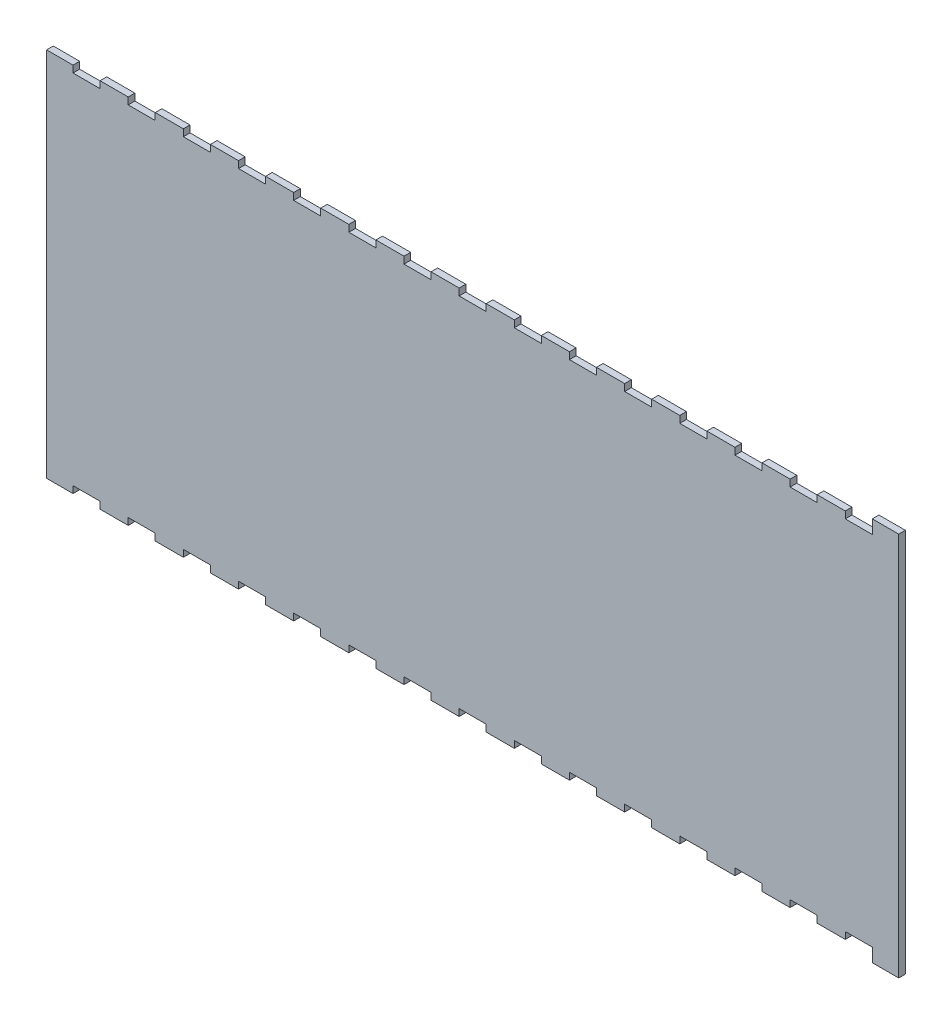
from build123d import *

# Parameters (mm, degrees)
BOSS_EXTRUDE1_DEPTH = 3.175


with BuildPart() as part:
    # Sketch1 → Boss-Extrude1 (new body)
    with BuildSketch(Plane.XY):
        Polygon((-12.6, 173.7122), (-25.5, 173.7122), (-25.5, 176.9872), (-38.907142857, 176.9872), (-38.907142857, 173.7122), (-51.807142857, 173.7122), (-51.807142857, 176.9872), (-65.214285714, 176.9872), (-65.214285714, 173.7122), (-78.114285714, 173.7122), (-78.114285714, 176.9872), (-91.521428571, 176.9872), (-91.521428571, 173.7122), (-104.421428571, 173.7122), (-104.421428571, 176.9872), (-117.828571429, 176.9872), (-117.828571429, 173.7122), (-130.728571429, 173.7122), (-130.728571429, 176.9872), (-144.135714286, 176.9872), (-144.135714286, 173.7122), (-157.035714286, 173.7122), (-157.035714286, 176.9872), (-170.442857143, 176.9872), (-170.442857143, 173.7122), (-183.342857143, 173.7122), (-183.342857143, 176.9872), (-196.75, 176.9872), (-196.75, 173.7122), (-209.65, 173.7122), (-209.65, 176.9872), (-223.057142857, 176.9872), (-223.057142857, 173.7122), (-235.957142857, 173.7122), (-235.957142857, 176.9872), (-249.364285714, 176.9872), (-249.364285714, 173.7122), (-262.264285714, 173.7122), (-262.264285714, 176.9872), (-275.671428571, 176.9872), (-275.671428571, 173.7122), (-288.571428571, 173.7122), (-288.571428571, 176.9872), (-301.978571429, 176.9872), (-301.978571429, 173.7122), (-314.878571429, 173.7122), (-314.878571429, 176.9872), (-328.285714286, 176.9872), (-328.285714286, 173.7122), (-341.185714286, 173.7122), (-341.185714286, 176.9872), (-354.592857143, 176.9872), (-354.592857143, 173.7122), (-367.492857143, 173.7122), (-367.492857143, 176.9872), (-380.9, 176.9872), (-380.9, 173.7122), (-393.8, 173.7122), (-393.8, 176.9872), (-406.4, 176.9872), (-406.4, 0), (-393.8, 0), (-393.8, 3.275), (-380.9, 3.275), (-380.9, 0), (-367.492857143, 0), (-367.492857143, 3.275), (-354.592857143, 3.275), (-354.592857143, 0), (-341.185714286, 0), (-341.185714286, 3.275), (-328.285714286, 3.275), (-328.285714286, 0), (-314.878571429, 0), (-314.878571429, 3.275), (-301.978571429, 3.275), (-301.978571429, 0), (-288.571428571, 0), (-288.571428571, 3.275), (-275.671428571, 3.275), (-275.671428571, 0), (-262.264285714, 0), (-262.264285714, 3.275), (-249.364285714, 3.275), (-249.364285714, 0), (-235.957142857, 0), (-235.957142857, 3.275), (-223.057142857, 3.275), (-223.057142857, 0), (-209.65, 0), (-209.65, 3.275), (-196.75, 3.275), (-196.75, 0), (-183.342857143, 0), (-183.342857143, 3.275), (-170.442857143, 3.275), (-170.442857143, 0), (-157.035714286, 0), (-157.035714286, 3.275), (-144.135714286, 3.275), (-144.135714286, 0), (-130.728571429, 0), (-130.728571429, 3.275), (-117.828571429, 3.275), (-117.828571429, 0), (-104.421428571, 0), (-104.421428571, 3.275), (-91.521428571, 3.275), (-91.521428571, 0), (-78.114285714, 0), (-78.114285714, 3.275), (-65.214285714, 3.275), (-65.214285714, 0), (-51.807142857, 0), (-51.807142857, 3.275), (-38.907142857, 3.275), (-38.907142857, 0), (-25.5, 0), (-25.5, 3.275), (-12.6, 3.275), (-12.6000002, -3.175), (0, -3.175), (0, 180.1622), (-12.6000002, 180.1622), align=None)
    extrude(amount=BOSS_EXTRUDE1_DEPTH)


solid = part.part
